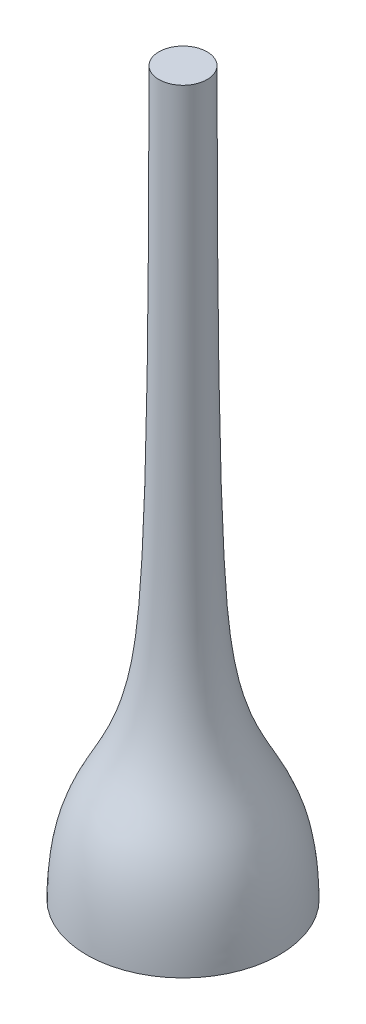
from build123d import *


with BuildPart() as part:
    # Sketch1 → Revolve8 (revolve)
    with BuildSketch(Plane.XY):
        with BuildLine():
            Line((0, 15), (0, 0))
            Line((0, 0), (2, 0))
            add(Edge.make_bspline(
                [(0.5, 15), (0.501667507, 9.660791997), (0.5714057, 5.994926019), (0.941978143, 2.03355611), (1.969950282, 2.351453197), (2, 0)],
                knots=[0, 0, 0, 0, 0.230231589, 0.330231589, 1, 1, 1, 1], degree=3))
            Line((0.5, 15), (0, 15))
        make_face()
    revolve(axis=Axis((0, 15, 0), (0, -1, 0)))


solid = part.part
